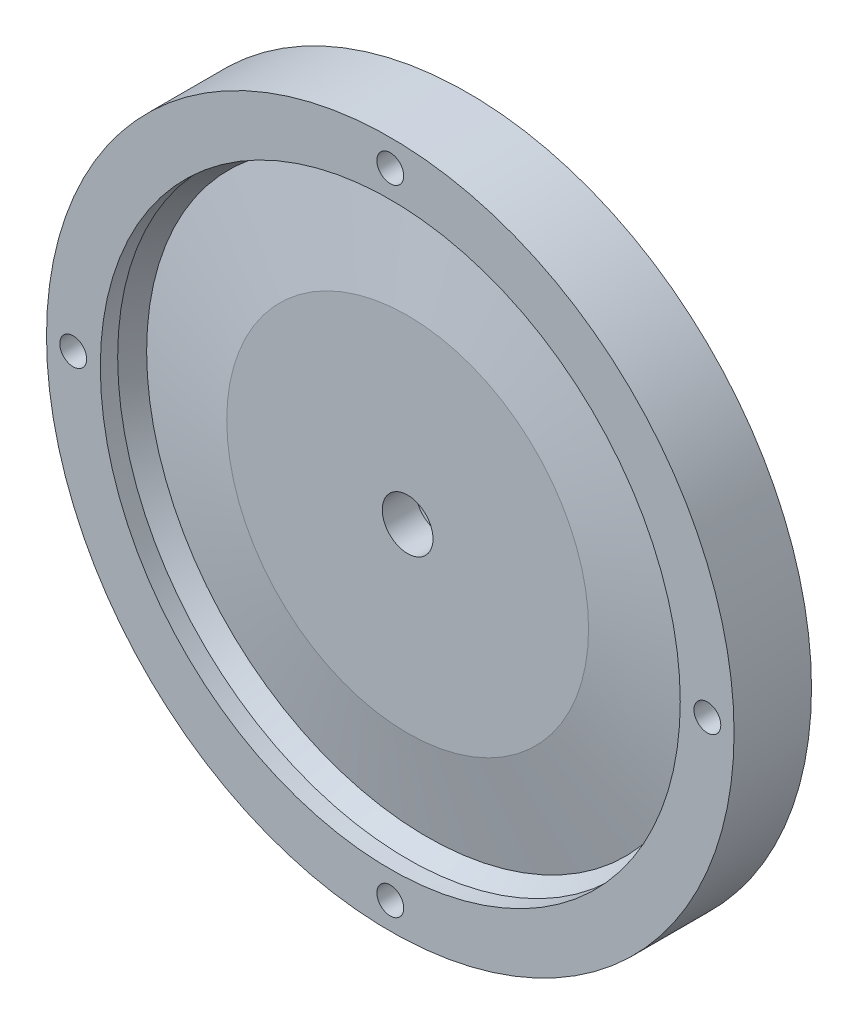
from build123d import *

# Parameters (mm, degrees)
SKETCH1_R               = 65.405
BOSS_EXTRUDE1_DEPTH     = 14.732
SKETCH2_R               = 55.1688
CUT_EXTRUDE1_DEPTH      = 3.302
F_1_4_20_TAPPED_HOLE1_D = 5.1054
SKETCH6_R               = 45.72
CUT_EXTRUDE2_DEPTH      = 5.08
SKETCH7_R               = 4.826
CUT_EXTRUDE3_DEPTH      = 10.652
BOSS_EXTRUDE2_DEPTH     = 6.223


with BuildPart() as part:
    # Sketch1 → Boss-Extrude1 (new body)
    with BuildSketch(Plane.XY):
        Circle(SKETCH1_R)
    extrude(amount=BOSS_EXTRUDE1_DEPTH)

    # Sketch2 → Cut-Extrude1 (cut)
    with BuildSketch(Plane.XY.offset(14.732)):
        Circle(SKETCH2_R)
    extrude(amount=-CUT_EXTRUDE1_DEPTH, mode=Mode.SUBTRACT)

    # Sketch3 → Cut-Revolve1 (revolve, cut)
    with BuildSketch(Plane(origin=(0, 0, 0), x_dir=(0, 0, -1), z_dir=(1, 0, 0))):
        Polygon((-11.43, 34.417), (-7.747, 53.34), (-11.43, 55.1688), align=None)
    revolve(axis=Axis((0, 0, 0), (0, 0, 1)), mode=Mode.SUBTRACT)

    # 1/4-20 Tapped Hole1 (through all)
    with Locations(Plane.XY.offset(14.732)):
        with Locations((0, 60.325), (60.325, 0), (0, -60.325), (-60.325, 0)):
            Hole(F_1_4_20_TAPPED_HOLE1_D / 2)

    # Sketch6 → Cut-Extrude2 (cut)
    with BuildSketch(Plane(origin=(0, 0, 0), x_dir=(-1, 0, 0), z_dir=(0, 0, -1))):
        Circle(SKETCH6_R)
    extrude(amount=-CUT_EXTRUDE2_DEPTH, mode=Mode.SUBTRACT)

    # Sketch7 → Cut-Extrude3 (cut, through all)
    with BuildSketch(Plane(origin=(0, 0, 5.08), x_dir=(-1, 0, 0), z_dir=(0, 0, -1))):
        Circle(SKETCH7_R)
    extrude(amount=-CUT_EXTRUDE3_DEPTH, mode=Mode.SUBTRACT)

    # Sketch8 → Boss-Extrude2 (add)
    with BuildSketch(Plane(origin=(0, 0, 5.08), x_dir=(-1, 0, 0), z_dir=(0, 0, -1))):
        with BuildLine():
            Line((-13.293205934, -6.35), (-9.42734439, -6.35))
            ThreePointArc((-9.42734439, -6.35), (0, -11.3665), (9.42734439, -6.35))
            Line((9.42734439, -6.35), (13.293205934, -6.35))
            ThreePointArc((13.293205934, -6.35), (0, -14.732), (-13.293205934, -6.35))
        make_face()
        with BuildLine():
            Line((-13.293205934, 6.35), (-9.42734439, 6.35))
            ThreePointArc((-9.42734439, 6.35), (0, 11.3665), (9.42734439, 6.35))
            Line((9.42734439, 6.35), (13.293205934, 6.35))
            ThreePointArc((13.293205934, 6.35), (0, 14.732), (-13.293205934, 6.35))
        make_face()
    extrude(amount=BOSS_EXTRUDE2_DEPTH)


solid = part.part
